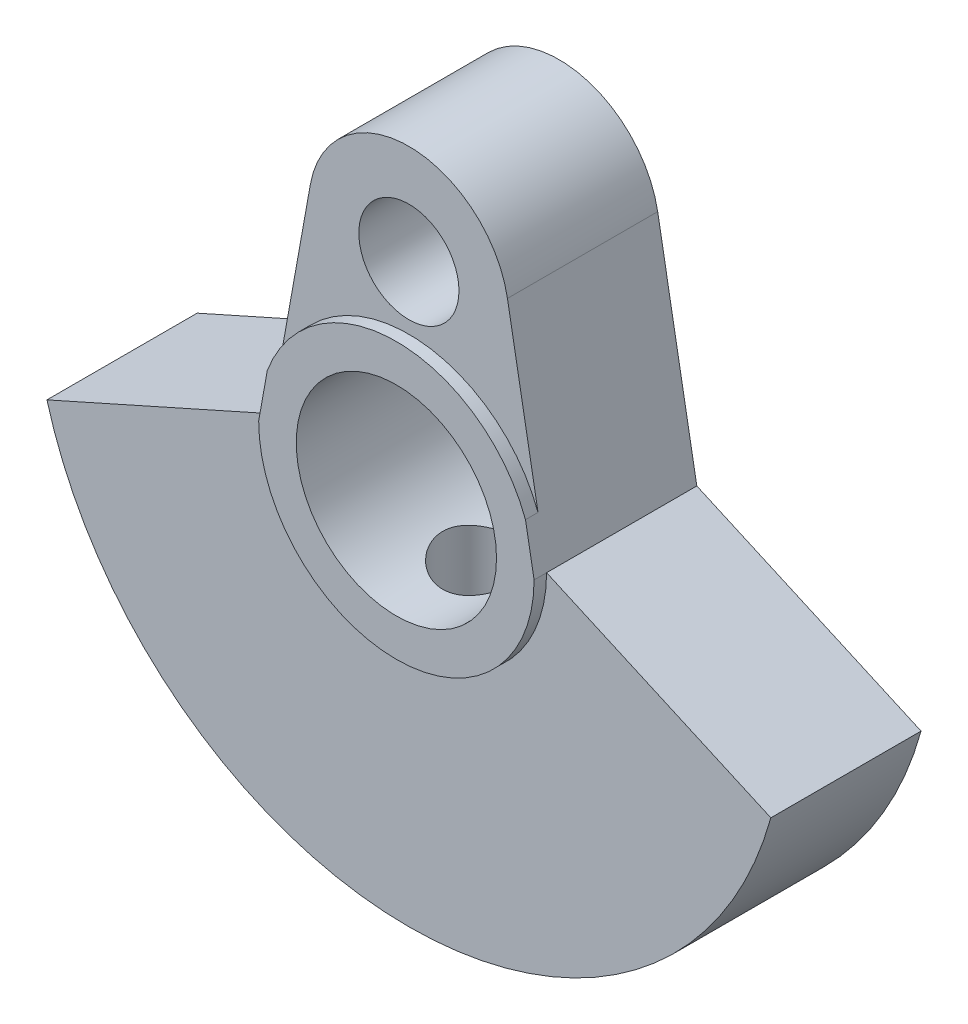
from build123d import *

# Parameters (mm, degrees)
SKETCH_1_R            = 4
SKETCH_1_R_2          = 2
EXTRUDE_1_DEPTH       = 6
SKETCH_2_R            = 4
EXTRUDE_2_DEPTH       = 0.5
SKETCH_5_R            = 2.747111961
EXTRUDE_3_DEPTH       = 6.5
HOLE_WIZARD_M41_D     = 3.3
HOLE_WIZARD_M41_DEPTH = 16.499
HOLE_WIZARD_M41_TIP   = 0.991420021
CUT_EXTRUDE_1_DEPTH   = 6.5


with BuildPart() as part:
    # Эскиз1 → Бобышка-Вытянуть1 (new body)
    with BuildSketch(Plane.XY):
        with BuildLine():
            Line((-5.5, 0), (-3.937070517, 8.70673598))
            ThreePointArc((-3.937070517, 8.70673598), (0, 12), (3.937070517, 8.70673598))
            Line((3.937070517, 8.70673598), (5.5, 0))
            Line((5.5, 0), (14.456832295, -4))
            ThreePointArc((14.456832295, -4), (0, -15), (-14.456832295, -4))
            Line((-14.456832295, -4), (-5.5, 0))
        make_face()
        Circle(SKETCH_1_R, mode=Mode.SUBTRACT)
        with Locations((0, 8)):
            Circle(SKETCH_1_R_2, mode=Mode.SUBTRACT)
    extrude(amount=EXTRUDE_1_DEPTH)

    # Эскиз2 → Бобышка-Вытянуть2 (add)
    with BuildSketch(Plane.XY.offset(6)):
        with BuildLine():
            Line((5.156610425, 1.912947706), (5.5, 0))
            ThreePointArc((5.5, 0), (0, -5.5), (-5.5, 0))
            Line((-5.5, 0), (-5.156610425, 1.912947706))
            ThreePointArc((-5.156610425, 1.912947706), (0, 5.5), (5.156610425, 1.912947706))
        make_face()
        Circle(SKETCH_2_R, mode=Mode.SUBTRACT)
    extrude(amount=EXTRUDE_2_DEPTH)

    # Эскиз5 → Бобышка-Вытянуть3 (add)
    with BuildSketch(Plane(origin=(0, -10, 0), x_dir=(1, 0, 0), z_dir=(0, 1, 0))):
        with Locations((0, -3)):
            Circle(SKETCH_5_R)
    extrude(amount=-EXTRUDE_3_DEPTH)

    # Отверстие обработанное метчиком M41
    with Locations(Plane(origin=(0, -16.5, 0), x_dir=(-1, 0, 0), z_dir=(0, -1, 0))):
        with Locations((0, -3)):
            Hole(HOLE_WIZARD_M41_D / 2, depth=HOLE_WIZARD_M41_DEPTH)
            with Locations((0, 0, -(HOLE_WIZARD_M41_DEPTH + HOLE_WIZARD_M41_TIP / 2))):  # 118° drill point
                Cone(0, HOLE_WIZARD_M41_D / 2, HOLE_WIZARD_M41_TIP, mode=Mode.SUBTRACT)

    # Эскиз8 → Вырез-Вытянуть1 (cut)
    with BuildSketch(Plane.XY.offset(6)):
        with BuildLine():
            Line((-5.46363589, -13.96956273), (-5.46363589, -17.421493936))
            ThreePointArc((-5.46363589, -17.421493936), (0, -18.258142515), (5.46363589, -17.421493936))
            Line((5.46363589, -17.421493936), (5.46363589, -13.96956273))
            ThreePointArc((5.46363589, -13.96956273), (0, -15), (-5.46363589, -13.96956273))
        make_face()
    extrude(amount=-CUT_EXTRUDE_1_DEPTH, mode=Mode.SUBTRACT)


solid = part.part
